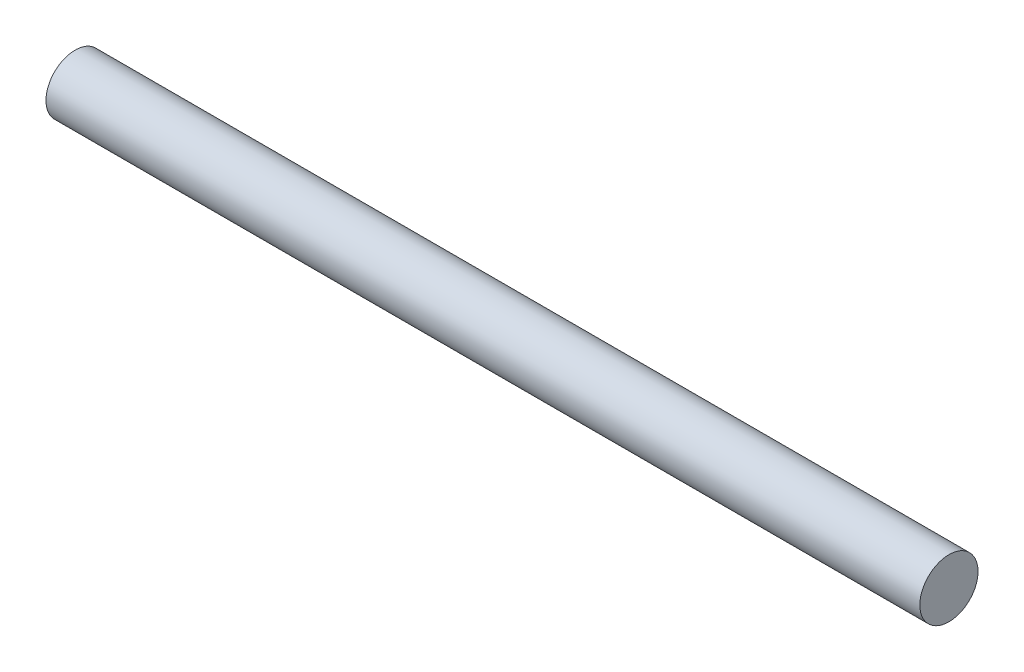
from build123d import *

# Parameters (mm, degrees)
SKETCH1_W = 180.17
SKETCH1_H = 6


with BuildPart() as part:
    # Sketch1 → Revolve1 (revolve)
    with BuildSketch(Plane(origin=(0, 0, 0), x_dir=(1, 0, 0), z_dir=(0, 1, 0))):
        with Locations((55.364538905, 9)):
            Rectangle(SKETCH1_W, SKETCH1_H)
    revolve(axis=Axis((-34.720461095, 0, -6), (1, 0, 0)))


solid = part.part
